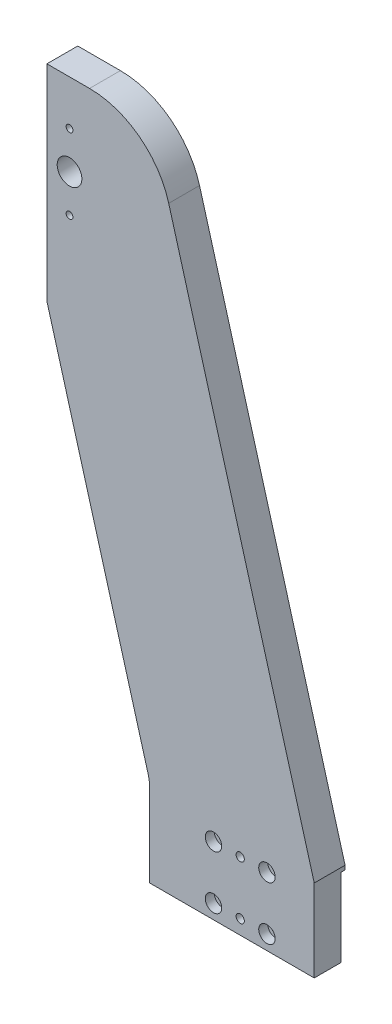
from build123d import *

# Parameters (mm, degrees)
SALIENTE_EXTRUIR1_DEPTH                              = 15
CROQUIS2_R                                           = 6
CORTAR_EXTRUIR1_DEPTH                                = 16
PERFORADOR_PARA_ROSCAR_PARA_MACHO_DE_ROS_D           = 3.3
PERFORADOR_PARA_ROSCAR_PARA_MACHO_DE_ROS_DEPTH       = 7
PERFORADOR_PARA_ROSCAR_PARA_MACHO_DE_ROS_TIP         = 0.991420021
CROQUIS9_W                                           = 80
CROQUIS9_H                                           = 38
CORTAR_EXTRUIR2_DEPTH                                = 2
TALADRO_ROSCADO_M41_D                                = 3.3
TALADRO_ROSCADO_M41_DEPTH                            = 15
TALADRO_ROSCADO_M41_TIP                              = 0.991420021
TALADROS_DE_ESPIGA_DE_4_0MM1_D                       = 4
TALADROS_DE_ESPIGA_DE_4_0MM1_DEPTH                   = 17
TALADROS_DE_ESPIGA_DE_4_0MM1_TIP                     = 1.201721238
TALADROS_DE_ESPIGA_DE_4_0MM3_D                       = 4
REFRENTADO_PARA_TORNILLO_CON_CABEZA_HUEC_D           = 4.5
REFRENTADO_PARA_TORNILLO_CON_CABEZA_HUEC_CBORE_D     = 8
REFRENTADO_PARA_TORNILLO_CON_CABEZA_HUEC_CBORE_DEPTH = 4.4


with BuildPart() as part:
    # Croquis1 → Saliente-Extruir1 (new body)
    with BuildSketch(Plane.XY):
        with BuildLine():
            Line((80, 0), (80, 40))
            Line((80, 40), (9.228509485, 290.860669242))
            ThreePointArc((9.228509485, 290.860669242), (-5.12786552, 311.893782856), (-29.268839302, 320))
            Line((-29.268839302, 320), (-50, 320))
            Line((-50, 320), (-50, 220))
            Line((-50, 220), (-0.751325607, 45.430334621))
            ThreePointArc((-0.751325607, 45.430334621), (-0.1887218, 42.741031935), (0, 40))
            Line((0, 40), (0, 0))
            Line((0, 0), (80, 0))
        make_face()
    extrude(amount=SALIENTE_EXTRUIR1_DEPTH)

    # Croquis2 → Cortar-Extruir1 (cut, through all)
    with BuildSketch(Plane(origin=(0, 0, 0), x_dir=(-1, 0, 0), z_dir=(0, 0, -1))):
        with Locations((39, 280)):
            Circle(CROQUIS2_R)
    extrude(amount=-CORTAR_EXTRUIR1_DEPTH, mode=Mode.SUBTRACT)

    # Perforador para roscar para macho de roscar para M44
    with Locations(Plane.XY.offset(15)):
        with Locations((-39, 298.25), (-39, 261.75)):
            Hole(PERFORADOR_PARA_ROSCAR_PARA_MACHO_DE_ROS_D / 2, depth=PERFORADOR_PARA_ROSCAR_PARA_MACHO_DE_ROS_DEPTH)
            with Locations((0, 0, -(PERFORADOR_PARA_ROSCAR_PARA_MACHO_DE_ROS_DEPTH + PERFORADOR_PARA_ROSCAR_PARA_MACHO_DE_ROS_TIP / 2))):  # 118° drill point
                Cone(0, PERFORADOR_PARA_ROSCAR_PARA_MACHO_DE_ROS_D / 2, PERFORADOR_PARA_ROSCAR_PARA_MACHO_DE_ROS_TIP, mode=Mode.SUBTRACT)

    # Croquis9 → Cortar-Extruir2 (cut)
    with BuildSketch(Plane(origin=(0, 0, 0), x_dir=(-1, 0, 0), z_dir=(0, 0, -1))):
        with Locations((-40, 19)):
            Rectangle(CROQUIS9_W, CROQUIS9_H)
    extrude(amount=-CORTAR_EXTRUIR2_DEPTH, mode=Mode.SUBTRACT)

    # Taladro roscado M41
    with Locations(Plane.ZY.offset(50)):
        with Locations((9, 312), (9, 248), (9, 291), (9, 269)):
            Hole(TALADRO_ROSCADO_M41_D / 2, depth=TALADRO_ROSCADO_M41_DEPTH)
            with Locations((0, 0, -(TALADRO_ROSCADO_M41_DEPTH + TALADRO_ROSCADO_M41_TIP / 2))):  # 118° drill point
                Cone(0, TALADRO_ROSCADO_M41_D / 2, TALADRO_ROSCADO_M41_TIP, mode=Mode.SUBTRACT)

    # Taladros de espiga de Ø4.0mm1
    with Locations(Plane.ZY.offset(50)):
        with Locations((9, 304), (9, 256)):
            Hole(TALADROS_DE_ESPIGA_DE_4_0MM1_D / 2, depth=TALADROS_DE_ESPIGA_DE_4_0MM1_DEPTH)
            with Locations((0, 0, -(TALADROS_DE_ESPIGA_DE_4_0MM1_DEPTH + TALADROS_DE_ESPIGA_DE_4_0MM1_TIP / 2))):  # 118° drill point
                Cone(0, TALADROS_DE_ESPIGA_DE_4_0MM1_D / 2, TALADROS_DE_ESPIGA_DE_4_0MM1_TIP, mode=Mode.SUBTRACT)

    # Taladros de espiga de Ø4.0mm3 (through all)
    with Locations(Plane.XY.offset(15)):
        with Locations((44, 33), (44, 7)):
            Hole(TALADROS_DE_ESPIGA_DE_4_0MM3_D / 2)

    # Refrentado para tornillo con cabeza hueca de M41 (through all)
    with Locations(Plane.XY.offset(15)):
        with Locations((57, 33), (31, 7), (31, 33), (57, 7)):
            CounterBoreHole(REFRENTADO_PARA_TORNILLO_CON_CABEZA_HUEC_D / 2, REFRENTADO_PARA_TORNILLO_CON_CABEZA_HUEC_CBORE_D / 2, REFRENTADO_PARA_TORNILLO_CON_CABEZA_HUEC_CBORE_DEPTH)


solid = part.part
